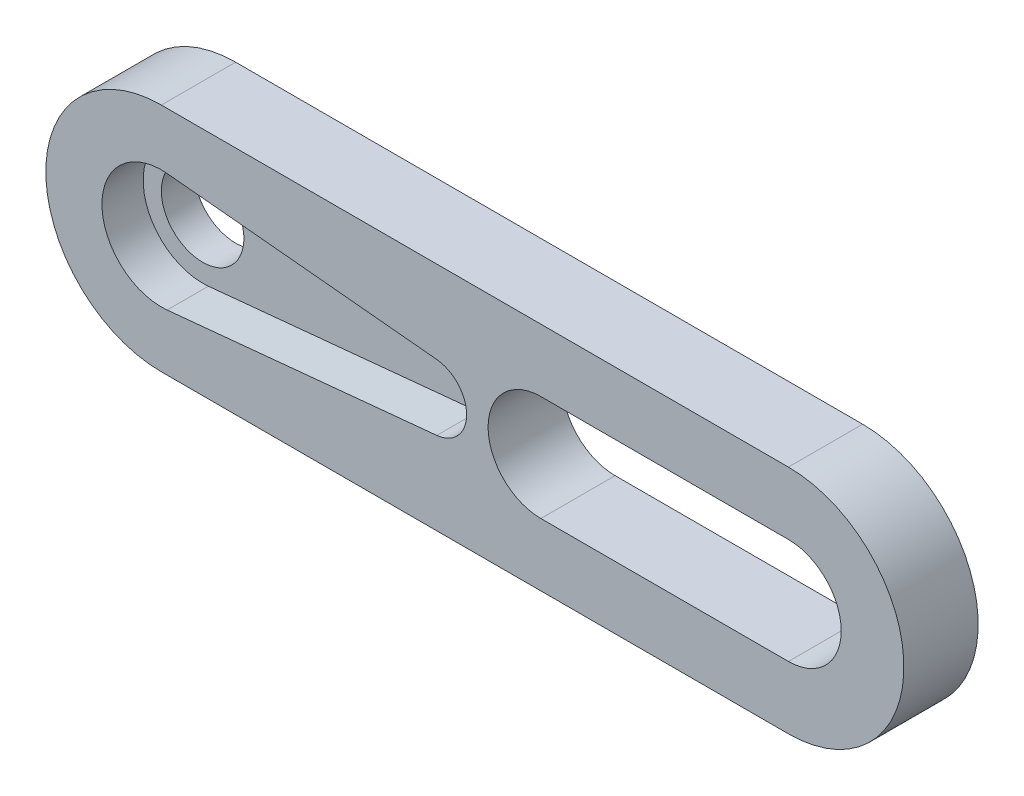
from build123d import *

# Parameters (mm, degrees)
MAIN_DEPTH            = 2.5
ESQUISSE2_R           = 2.5
ORIGINALBRACKET_DEPTH = 2
CUT_EXTRUDE1_DEPTH    = 3


with BuildPart() as part:
    # Esquisse1 → Main (new body)
    with BuildSketch(Plane.XY):
        with BuildLine():
            Line((0, 7), (38, 7))
            ThreePointArc((38, 7), (45, 0), (38, -7))
            Line((38, -7), (0, -7))
            ThreePointArc((0, -7), (-7, 0), (0, 7))
        make_face()
        with BuildLine():
            Line((0.349090909, 3.583034404), (16.693939394, 1.990574669))
            ThreePointArc((16.693939394, 1.990574669), (18.5, 0), (16.693939394, -1.990574669))
            Line((16.693939394, -1.990574669), (0.349090909, -3.583034404))
            ThreePointArc((0.349090909, -3.583034404), (-3.6, 0), (0.349090909, 3.583034404))
        make_face(mode=Mode.SUBTRACT)
        with BuildLine():
            Line((23, 3.2), (38, 3.2))
            ThreePointArc((38, 3.2), (41.2, 0), (38, -3.2))
            Line((38, -3.2), (23, -3.2))
            ThreePointArc((23, -3.2), (19.8, 0), (23, 3.2))
        make_face(mode=Mode.SUBTRACT)
    extrude(amount=MAIN_DEPTH)

    # Esquisse2 → OriginalBracket (add)
    with BuildSketch(Plane(origin=(0, 0, 0), x_dir=(-1, 0, 0), z_dir=(0, 0, -1))):
        with BuildLine():
            Line((0, -7), (-38, -7))
            ThreePointArc((-38, -7), (-45, 0), (-38, 7))
            Line((-38, 7), (0, 7))
            ThreePointArc((0, 7), (7, 0), (0, -7))
        make_face()
        Circle(ESQUISSE2_R, mode=Mode.SUBTRACT)
    extrude(amount=ORIGINALBRACKET_DEPTH)

    # Sketch1 → Cut-Extrude1 (cut, through all)
    with BuildSketch(Plane.XY):
        with BuildLine():
            Line((23, 3.2), (38, 3.2))
            ThreePointArc((38, 3.2), (41.2, 0), (38, -3.2))
            Line((38, -3.2), (23, -3.2))
            ThreePointArc((23, -3.2), (19.8, 0), (23, 3.2))
        make_face()
    extrude(amount=-CUT_EXTRUDE1_DEPTH, mode=Mode.SUBTRACT)


solid = part.part
